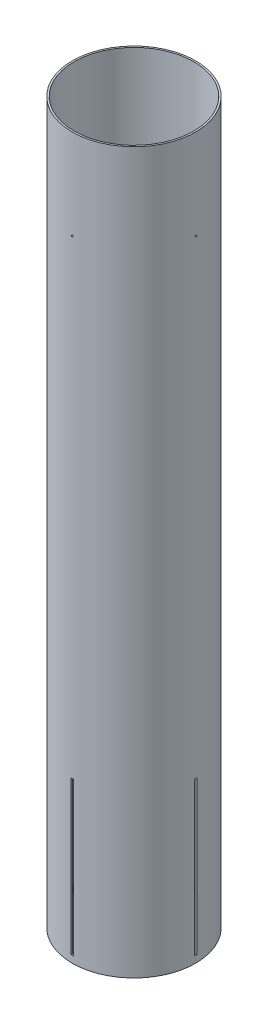
from build123d import *

# Parameters (mm, degrees)
SKETCH1_R                 = 78.359
SKETCH1_R_2               = 76.2
BOSS_EXTRUDE1_DEPTH       = 914.4
FIN_SLOTS_DEPTH           = 922.090454712
CIRPATTERN1_COUNT         = 4
SKETCH3_R                 = 3.175
RAIL_BUTTONS_DEPTH        = 922.090454712
SKETCH2_4_R               = 1.0922
SHEAR_SCREW_HOLES_DEPTH   = 922.090454829
SHEAR_SCREW_PATTERN_COUNT = 4


with BuildPart() as part:
    # Sketch1 → Boss-Extrude1 (new body)
    with BuildSketch(Plane(origin=(0, 0, 0), x_dir=(1, 0, 0), z_dir=(0, 1, 0))):
        Circle(SKETCH1_R)
        Circle(SKETCH1_R_2, mode=Mode.SUBTRACT)
    extrude(amount=BOSS_EXTRUDE1_DEPTH)

    # Sketch2 → Fin Slots (cut, through all)
    with BuildSketch(Plane(origin=(0, 0, 0), x_dir=(0, 0, -1), z_dir=(1, 0, 0))):
        Polygon((0, 8.89), (1.5875, 8.89), (1.5875, 203.2), (-1.5875, 203.2), (-1.5875, 8.89), align=None)
    fin_slots = extrude(amount=-FIN_SLOTS_DEPTH, mode=Mode.SUBTRACT)

    # CirPattern1: Fin Slots ×4 about axis
    cirpattern1_axis = Axis((0, 0, 0), (0, 1, 0))
    for i in range(1, CIRPATTERN1_COUNT):
        add(fin_slots.rotate(cirpattern1_axis, i * 360 / CIRPATTERN1_COUNT), mode=Mode.SUBTRACT)

    # Sketch3 → Rail Buttons (cut, through all)
    with BuildSketch(Plane(origin=(0, 0, 0), x_dir=(0.7071067811865477, 0, -0.7071067811865475), z_dir=(0.7071067811865475, 0, 0.7071067811865477))):
        with Locations((0, 127)):
            Circle(SKETCH3_R)
        with Locations((0, 742.95)):
            Circle(SKETCH3_R)
    extrude(amount=-RAIL_BUTTONS_DEPTH, mode=Mode.SUBTRACT)

    # Sketch2_4 → Shear Screw Holes (cut, through all)
    with BuildSketch(Plane(origin=(0, 0, 0), x_dir=(0, 0, -1), z_dir=(1, 0, 0))):
        with Locations((0, 800.1)):
            Circle(SKETCH2_4_R)
    shear_screw_holes = extrude(amount=-SHEAR_SCREW_HOLES_DEPTH, mode=Mode.SUBTRACT)

    # Shear Screw Pattern: Shear Screw Holes ×4 about axis
    shear_screw_pattern_axis = Axis((0, 914.4, 0), (0, -1, 0))
    for i in range(1, SHEAR_SCREW_PATTERN_COUNT):
        add(shear_screw_holes.rotate(shear_screw_pattern_axis, i * 360 / SHEAR_SCREW_PATTERN_COUNT), mode=Mode.SUBTRACT)


solid = part.part
